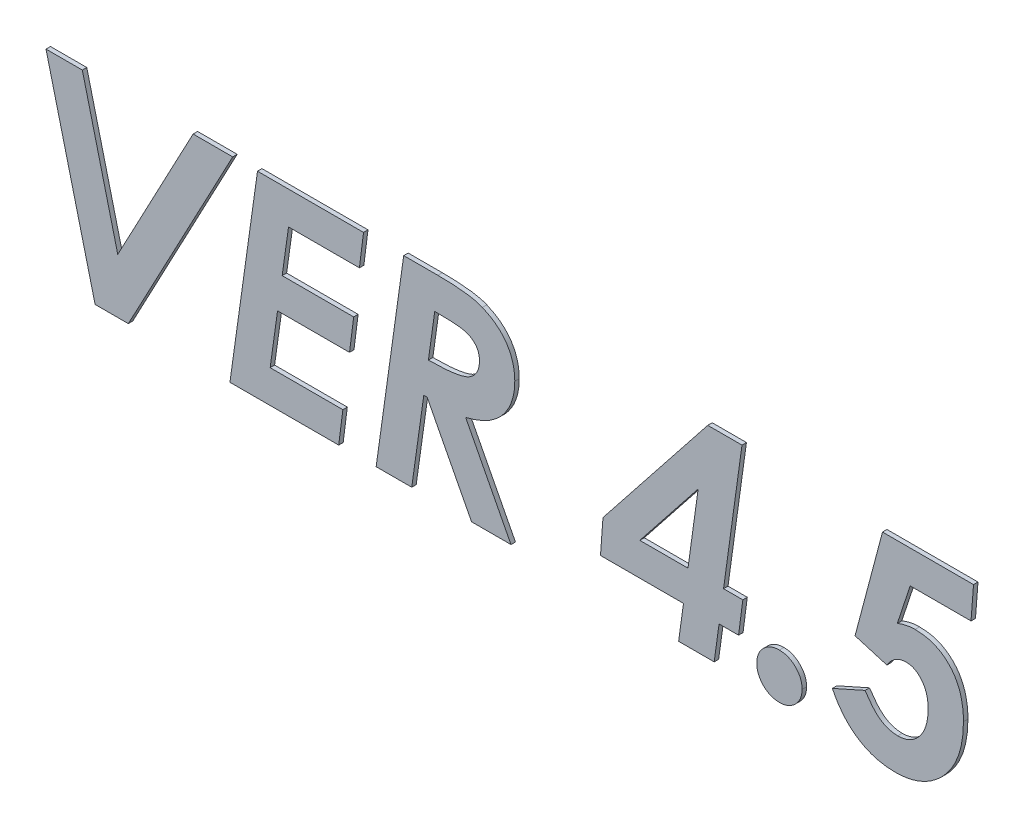
from build123d import *

# Parameters (mm, degrees)
BOSS_EXTRUDE1_DEPTH   = 0.5
BOSS_EXTRUDE1_2_DEPTH = 0.5
BOSS_EXTRUDE1_3_DEPTH = 0.5
BOSS_EXTRUDE1_4_DEPTH = 0.5
BOSS_EXTRUDE1_5_DEPTH = 0.5
BOSS_EXTRUDE1_6_DEPTH = 0.5


with BuildPart() as part:
    # Sketch1 → Boss-Extrude1 (new body)
    with BuildSketch(Plane.XY):
        Polygon((1.419070513, 22), (5.482371795, 22), (9.448717949, 6.116987179), (17.879407051, 22), (22.312900641, 22), (10.629807692, 0), (6.914663462, 0), align=None)
    extrude(amount=BOSS_EXTRUDE1_DEPTH)


with BuildPart() as body_2:
    # Sketch1 → Boss-Extrude1 2 (new body)
    with BuildSketch(Plane.XY):
        Polygon((25.084935897, 22), (36.948717949, 22), (36.485977564, 18.333333333), (28.557692308, 18.333333333), (27.84375, 13.256410256), (35.846955128, 13.256410256), (35.379807692, 9.58974359), (27.328125, 9.58974359), (26.499599359, 3.666666667), (34.635016026, 3.666666667), (34.172275641, 0), (22, 0), align=None)
    extrude(amount=BOSS_EXTRUDE1_2_DEPTH)


with BuildPart() as body_3:
    # Sketch1 → Boss-Extrude1 3 (new body)
    with BuildSketch(Plane.XY):
        with BuildLine():
            Line((41.443910256, 22), (45.264823718, 22))
            add(Edge.make_bspline(
                [(45.264823718, 22), (45.548376804, 21.998841241), (46.095101241, 21.996607015), (46.881308765, 21.964836333), (47.602913521, 21.916904165), (48.259057488, 21.853648173), (48.850288478, 21.765884023), (49.375376991, 21.660505581), (49.837676884, 21.543152003), (50.114916499, 21.434099403), (50.244791667, 21.383012821)],
                knots=[0, 0, 0, 0, 0.000850607, 0.001640072, 0.002360055, 0.003020025, 0.003617111, 0.00415211, 0.004626764, 0.005045085, 0.005045085, 0.005045085, 0.005045085], degree=3))
            add(Edge.make_bspline(
                [(50.244791667, 21.383012821), (50.391014404, 21.317073351), (50.676856715, 21.188172123), (51.086452085, 20.969676632), (51.470006269, 20.734297689), (51.821162545, 20.473160737), (52.147331393, 20.197261412), (52.446490277, 19.903975546), (52.716230339, 19.588802109), (52.959382448, 19.257394152), (53.175592247, 18.910180307), (53.361186086, 18.545448364), (53.521665865, 18.16628624), (53.646987269, 17.768567987), (53.751144421, 17.357067766), (53.81850949, 16.929189292), (53.865917846, 16.486375869), (53.869813361, 16.185763434), (53.871794872, 16.032852564)],
                knots=[0, 0, 0, 0, 0.000481096, 0.000940466, 0.001391732, 0.001829807, 0.002251896, 0.002672602, 0.003085126, 0.003495006, 0.003904696, 0.004310719, 0.004721592, 0.005138309, 0.005560513, 0.005993773, 0.006436676, 0.0068952, 0.0068952, 0.0068952, 0.0068952], degree=3))
            add(Edge.make_bspline(
                [(53.871794872, 16.032852564), (53.867134858, 15.844685214), (53.857935235, 15.473212402), (53.797822967, 14.925425767), (53.685706118, 14.399767621), (53.534718536, 13.894582093), (53.347657048, 13.406598163), (53.106416781, 12.944307117), (52.827573034, 12.499654098), (52.505536963, 12.078468794), (52.145584116, 11.676887512), (51.729964693, 11.318543764), (51.281671345, 10.979337915), (50.782287551, 10.682012222), (50.245547598, 10.40582313), (49.659209208, 10.171818945), (49.034277034, 9.955869202), (48.596085988, 9.847789362), (48.371794872, 9.792467949)],
                knots=[0, 0, 0, 0, 0.000564533, 0.001114479, 0.001650366, 0.002174639, 0.002695137, 0.003215487, 0.003736359, 0.004267861, 0.004804436, 0.005350857, 0.005911437, 0.006488878, 0.007091985, 0.007720511, 0.008381098, 0.009073777, 0.009073777, 0.009073777, 0.009073777], degree=3))
            Line((48.371794872, 9.792467949), (53.448717949, 0))
            Line((53.448717949, 0), (49.037259615, 0))
            Line((49.037259615, 0), (44.066105769, 9.58974359))
            Line((44.066105769, 9.58974359), (43.69150641, 9.58974359))
            Line((43.69150641, 9.58974359), (42.342948718, 0))
            Line((42.342948718, 0), (38.358974359, 0))
            Line((38.358974359, 0), (41.443910256, 22))
        make_face()
        with BuildLine():
            add(Edge.make_bspline(
                [(44.20713141, 13.256410256), (44.490693019, 13.259043278), (45.033075037, 13.264079586), (45.807703774, 13.299110765), (46.506240191, 13.354447303), (47.126669703, 13.433526829), (47.670624371, 13.527049292), (48.135793455, 13.643805407), (48.524309073, 13.782626303), (48.842299105, 13.947254023), (49.099892933, 14.140543025), (49.322851459, 14.346812687), (49.508504544, 14.577708739), (49.661684979, 14.829354916), (49.779827999, 15.102272808), (49.865027382, 15.398311397), (49.912134797, 15.715496813), (49.919376554, 15.934280399), (49.923076923, 16.046073718)],
                knots=[0, 0, 0, 0, 0.000850664, 0.001627106, 0.002325773, 0.00295221, 0.00350288, 0.003980674, 0.004389201, 0.004738138, 0.005050168, 0.00535259, 0.005647171, 0.005935891, 0.006233914, 0.006536592, 0.006857581, 0.007192981, 0.007192981, 0.007192981, 0.007192981], degree=3))
            add(Edge.make_bspline(
                [(49.923076923, 16.046073718), (49.91828694, 16.1728312), (49.908995028, 16.418723339), (49.828623788, 16.772878929), (49.691191734, 17.09414615), (49.498049712, 17.379453544), (49.257018851, 17.631023481), (48.962974411, 17.838220342), (48.619276344, 18.001324137), (48.297313239, 18.109081872), (47.992558285, 18.171497911), (47.708467949, 18.21343313), (47.372112922, 18.253899119), (46.98248147, 18.283822444), (46.54004198, 18.303616163), (46.045019713, 18.322850022), (45.498413323, 18.329689691), (45.116452002, 18.332082022), (44.916666667, 18.333333333)],
                knots=[0, 0, 0, 0, 0.000379928, 0.000737008, 0.001082477, 0.001422277, 0.001765122, 0.002122202, 0.002494722, 0.002903058, 0.003137296, 0.003427125, 0.003764401, 0.004153446, 0.004599104, 0.005093008, 0.005639554, 0.006238929, 0.006238929, 0.006238929, 0.006238929], degree=3))
            Line((44.916666667, 18.333333333), (44.20713141, 13.256410256))
        make_face(mode=Mode.SUBTRACT)
    extrude(amount=BOSS_EXTRUDE1_3_DEPTH)


with BuildPart() as body_4:
    # Sketch1 → Boss-Extrude1 4 (new body)
    with BuildSketch(Plane.XY):
        Polygon((75.466346154, 22.564102564), (79.296073718, 22.564102564), (77.233573718, 7.615384615), (79.388621795, 7.615384615), (78.912660256, 3.948717949), (76.731169872, 3.948717949), (76.184695513, 0), (72.205128205, 0), (72.751602564, 3.948717949), (63.461538462, 3.948717949), (63.743589744, 7.765224359), align=None)
        Polygon((74.391025641, 15.856570513), (67.864182692, 7.615384615), (73.25400641, 7.615384615), align=None, mode=Mode.SUBTRACT)
    extrude(amount=BOSS_EXTRUDE1_4_DEPTH)


with BuildPart() as body_5:
    # Sketch1 → Boss-Extrude1 5 (new body)
    with BuildSketch(Plane.XY):
        with BuildLine():
            add(Edge.make_bspline(
                [(83.487179487, 4.794871795), (83.655772599, 4.787600389), (83.98748891, 4.773293494), (84.461892735, 4.623718223), (84.901153267, 4.390862539), (85.28551112, 4.064930876), (85.61332073, 3.679951145), (85.856698985, 3.244102467), (85.997676158, 2.761433412), (86.01615439, 2.42773131), (86.025641026, 2.256410256)],
                knots=[0, 0, 0, 0, 0.000504333, 0.000992303, 0.001477339, 0.001987435, 0.00249415, 0.002987268, 0.003473983, 0.003987494, 0.003987494, 0.003987494, 0.003987494], degree=3))
            add(Edge.make_bspline(
                [(86.025641026, 2.256410256), (86.015894187, 2.088075472), (85.996748536, 1.757416545), (85.856937976, 1.27732267), (85.611881903, 0.841505096), (85.28737052, 0.451894987), (84.899556867, 0.127921364), (84.464103039, -0.11349386), (83.986232903, -0.25326775), (83.655534413, -0.272341201), (83.487179487, -0.282051282)],
                knots=[0, 0, 0, 0, 0.000504737, 0.000991452, 0.001484569, 0.001994665, 0.002504761, 0.002991895, 0.00347861, 0.003983347, 0.003983347, 0.003983347, 0.003983347], degree=3))
            add(Edge.make_bspline(
                [(83.487179487, -0.282051282), (83.317392069, -0.272283471), (82.983879336, -0.2530966), (82.502552214, -0.114544351), (82.06617739, 0.128173691), (81.678243835, 0.45062991), (81.357622981, 0.84179481), (81.11816404, 1.278456296), (80.977365657, 1.757299412), (80.95838221, 2.088035958), (80.948717949, 2.256410256)],
                knots=[0, 0, 0, 0, 0.000509124, 0.00100007, 0.001487204, 0.0019973, 0.00250459, 0.002995595, 0.00348231, 0.003987048, 0.003987048, 0.003987048, 0.003987048], degree=3))
            add(Edge.make_bspline(
                [(80.948717949, 2.256410256), (80.958119771, 2.427771707), (80.976432803, 2.761552493), (81.118403549, 3.242970833), (81.356192493, 3.679639708), (81.680107241, 4.06621239), (82.064583129, 4.390602243), (82.504758769, 4.62476809), (82.982629211, 4.77313196), (83.317154232, 4.787545823), (83.487179487, 4.794871795)],
                knots=[0, 0, 0, 0, 0.000513511, 0.001000226, 0.001491232, 0.001995122, 0.002505218, 0.002990254, 0.003482445, 0.003991168, 0.003991168, 0.003991168, 0.003991168], degree=3))
        make_face()
    extrude(amount=BOSS_EXTRUDE1_5_DEPTH)


with BuildPart() as body_6:
    # Sketch1 → Boss-Extrude1 6 (new body)
    with BuildSketch(Plane.XY):
        with BuildLine():
            Line((95.020432692, 22), (105.205128205, 22))
            Line((105.205128205, 22), (104.923076923, 18.333333333))
            Line((104.923076923, 18.333333333), (98.118589744, 18.333333333))
            Line((98.118589744, 18.333333333), (96.673076923, 13.961538462))
            add(Edge.make_bspline(
                [(96.673076923, 13.961538462), (96.83041594, 14.027030282), (97.145187683, 14.158052928), (97.640311314, 14.286085496), (98.146564634, 14.36998368), (98.488439599, 14.379713864), (98.660657051, 14.384615385)],
                knots=[0, 0, 0, 0, 0.000510686, 0.001021676, 0.001530304, 0.002046606, 0.002046606, 0.002046606, 0.002046606], degree=3))
            add(Edge.make_bspline(
                [(98.660657051, 14.384615385), (98.859214442, 14.379410239), (99.247499495, 14.369231417), (99.815978151, 14.293172154), (100.355651158, 14.166812384), (100.864590131, 13.984277023), (101.34498456, 13.755270241), (101.791563809, 13.470545931), (102.209670403, 13.136732995), (102.595925279, 12.75470785), (102.94575378, 12.325574703), (103.250613613, 11.852739763), (103.50647554, 11.336077404), (103.720043682, 10.78072969), (103.874611702, 10.179351194), (103.995011733, 9.540849293), (104.06605504, 8.858305797), (104.073231038, 8.389722964), (104.076923077, 8.148637821)],
                knots=[0, 0, 0, 0, 0.000595539, 0.001164595, 0.001717237, 0.002255294, 0.002783552, 0.003310504, 0.003840469, 0.004385822, 0.004937144, 0.005498244, 0.006069803, 0.00666402, 0.007279762, 0.007929769, 0.008612108, 0.0093352, 0.0093352, 0.0093352, 0.0093352], degree=3))
            add(Edge.make_bspline(
                [(104.076923077, 8.148637821), (104.069987323, 7.831077099), (104.056400375, 7.208984492), (103.954940946, 6.299009084), (103.782491625, 5.436921643), (103.546967741, 4.618765676), (103.230521953, 3.852373022), (102.857006671, 3.12752537), (102.407647983, 2.453364983), (101.894117753, 1.832925847), (101.334613915, 1.268714282), (100.730149156, 0.782639797), (100.097763329, 0.363843976), (99.429041347, 0.021056774), (98.723172453, -0.236778687), (97.987630764, -0.429957798), (97.216963449, -0.539575485), (96.692504797, -0.555844287), (96.426282051, -0.564102564)],
                knots=[0, 0, 0, 0, 0.000952576, 0.001866069, 0.002742463, 0.003587561, 0.00441577, 0.005225924, 0.006030196, 0.006841058, 0.007638819, 0.008409688, 0.00916386, 0.009910852, 0.01065826, 0.011413976, 0.012188678, 0.01298734, 0.01298734, 0.01298734, 0.01298734], degree=3))
            add(Edge.make_bspline(
                [(96.426282051, -0.564102564), (96.236663193, -0.560735694), (95.862549077, -0.554092929), (95.308562806, -0.500672839), (94.771112027, -0.408250024), (94.249365703, -0.278213911), (93.740889345, -0.122219293), (93.249771521, 0.076692675), (92.778571212, 0.318269363), (92.317378938, 0.585196098), (91.877835599, 0.893085334), (91.461845204, 1.240669973), (91.06446885, 1.619317295), (90.689086235, 2.034932717), (90.336822014, 2.487304406), (90.000541917, 2.970607396), (89.692088957, 3.493966959), (89.505323134, 3.859573588), (89.41025641, 4.045673077)],
                knots=[0, 0, 0, 0, 0.000568783, 0.001122197, 0.001667764, 0.002203271, 0.002734334, 0.003262188, 0.003790391, 0.004321747, 0.004859696, 0.005398006, 0.005946609, 0.006505123, 0.00707641, 0.007665638, 0.008270288, 0.008897144, 0.008897144, 0.008897144, 0.008897144], degree=3))
            Line((89.41025641, 4.045673077), (93.063701923, 5.676282051))
            add(Edge.make_bspline(
                [(93.063701923, 5.676282051), (93.217852561, 5.44792954), (93.50705973, 5.019509752), (93.95873055, 4.448687727), (94.405673664, 3.998099996), (94.845006081, 3.650322307), (95.294583981, 3.40131632), (95.756396819, 3.22818316), (96.237991365, 3.123480193), (96.565329881, 3.109574915), (96.73036859, 3.102564103)],
                knots=[0, 0, 0, 0, 0.000826425, 0.001550483, 0.002179967, 0.002726513, 0.00322562, 0.00371512, 0.004201755, 0.004696602, 0.004696602, 0.004696602, 0.004696602], degree=3))
            add(Edge.make_bspline(
                [(96.73036859, 3.102564103), (96.849615191, 3.105443839), (97.085134103, 3.111131484), (97.430717181, 3.171699635), (97.761947824, 3.263295141), (98.078370261, 3.391093884), (98.374382592, 3.560901665), (98.655773663, 3.765792522), (98.919044292, 4.010665827), (99.170337406, 4.285266547), (99.393686379, 4.595712409), (99.59351283, 4.928841744), (99.755837218, 5.291099609), (99.892828088, 5.673840385), (99.999279184, 6.082350996), (100.070979563, 6.514649505), (100.1237354, 6.970669241), (100.126689949, 7.283222999), (100.128205128, 7.443509615)],
                knots=[0, 0, 0, 0, 0.000357406, 0.000705898, 0.001049139, 0.001387134, 0.001726592, 0.00207037, 0.002429078, 0.002803496, 0.003185183, 0.003574428, 0.003966878, 0.004373905, 0.004792922, 0.005231264, 0.005687771, 0.006168322, 0.006168322, 0.006168322, 0.006168322], degree=3))
            add(Edge.make_bspline(
                [(100.128205128, 7.443509615), (100.120485945, 7.677748275), (100.105687211, 8.126815969), (99.97295193, 8.76648748), (99.748611576, 9.335285552), (99.434883221, 9.8204154), (99.062563385, 10.214617044), (98.646233795, 10.50688373), (98.185088519, 10.685702902), (97.863043539, 10.707107012), (97.699919872, 10.717948718)],
                knots=[0, 0, 0, 0, 0.000702106, 0.001346033, 0.001949171, 0.002526159, 0.00306853, 0.003566059, 0.004041633, 0.004529782, 0.004529782, 0.004529782, 0.004529782], degree=3))
            add(Edge.make_bspline(
                [(97.699919872, 10.717948718), (97.589536364, 10.713263311), (97.371439118, 10.70400582), (97.050558446, 10.643888034), (96.750968251, 10.528975729), (96.462243277, 10.385175898), (96.19859971, 10.186909398), (95.949311531, 9.949994845), (95.713826712, 9.67174717), (95.579160195, 9.460734499), (95.509615385, 9.351762821)],
                knots=[0, 0, 0, 0, 0.000331263, 0.000654513, 0.000973804, 0.001291142, 0.001619046, 0.001958846, 0.002321673, 0.002709142, 0.002709142, 0.002709142, 0.002709142], degree=3))
            Line((95.509615385, 9.351762821), (91.948717949, 10.409455128))
            Line((91.948717949, 10.409455128), (95.020432692, 22))
        make_face()
    extrude(amount=BOSS_EXTRUDE1_6_DEPTH)


solid = Compound([part.part, body_2.part, body_3.part, body_4.part, body_5.part, body_6.part])
